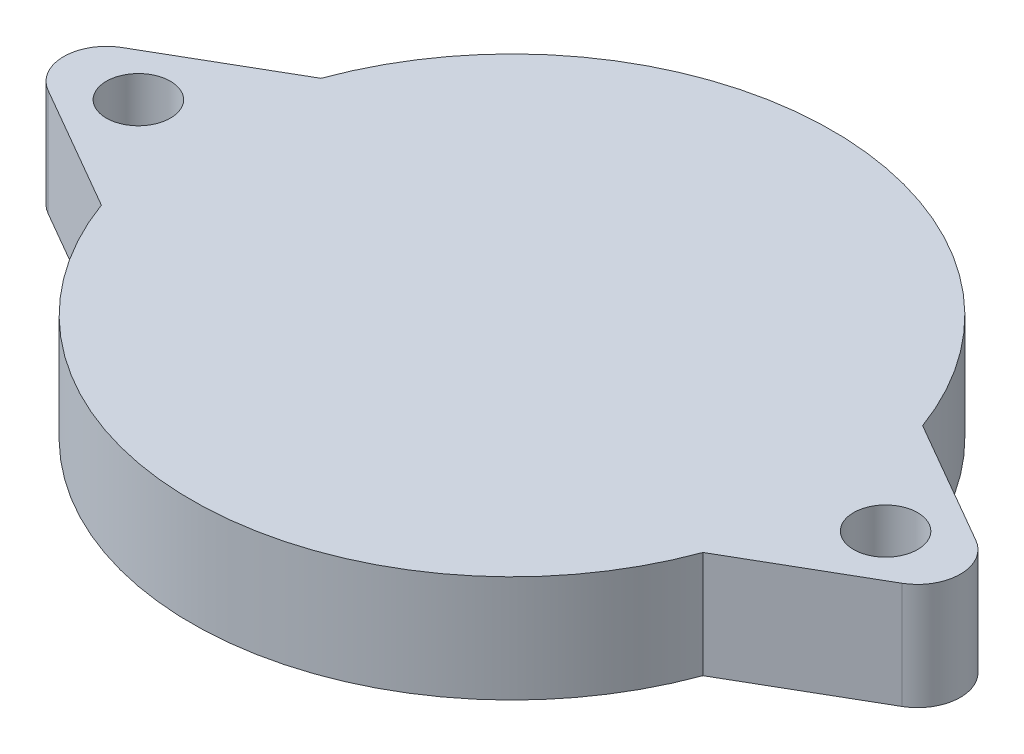
from build123d import *

# Parameters (mm, degrees)
SKETCH_1_R      = 1.5
EXTRUDE_1_DEPTH = 5


with BuildPart() as part:
    # 草圖1 → 填料-伸長1 (new body)
    with BuildSketch(Plane(origin=(0, 0, 0), x_dir=(1, 0, 0), z_dir=(0, 1, 0))):
        with BuildLine():
            Line((-20, -1.732050808), (-14.090413659, -5.143952072))
            ThreePointArc((-14.090413659, -5.143952072), (0, -15), (14.090413659, -5.143952072))
            Line((14.090413659, -5.143952072), (20, -1.732050808))
            ThreePointArc((20, -1.732050808), (21, 0), (20, 1.732050808))
            Line((20, 1.732050808), (14.090413659, 5.143952072))
            ThreePointArc((14.090413659, 5.143952072), (8.597695008, 12.291445828), (0, 15))
            ThreePointArc((0, 15), (-8.597695008, 12.291445828), (-14.090413659, 5.143952072))
            Line((-14.090413659, 5.143952072), (-20, 1.732050808))
            ThreePointArc((-20, 1.732050808), (-21, 0), (-20, -1.732050808))
        make_face()
        with Locations((-17.5, 0)):
            Circle(SKETCH_1_R, mode=Mode.SUBTRACT)
        with Locations((17.5, 0)):
            Circle(SKETCH_1_R, mode=Mode.SUBTRACT)
    extrude(amount=EXTRUDE_1_DEPTH)


solid = part.part
